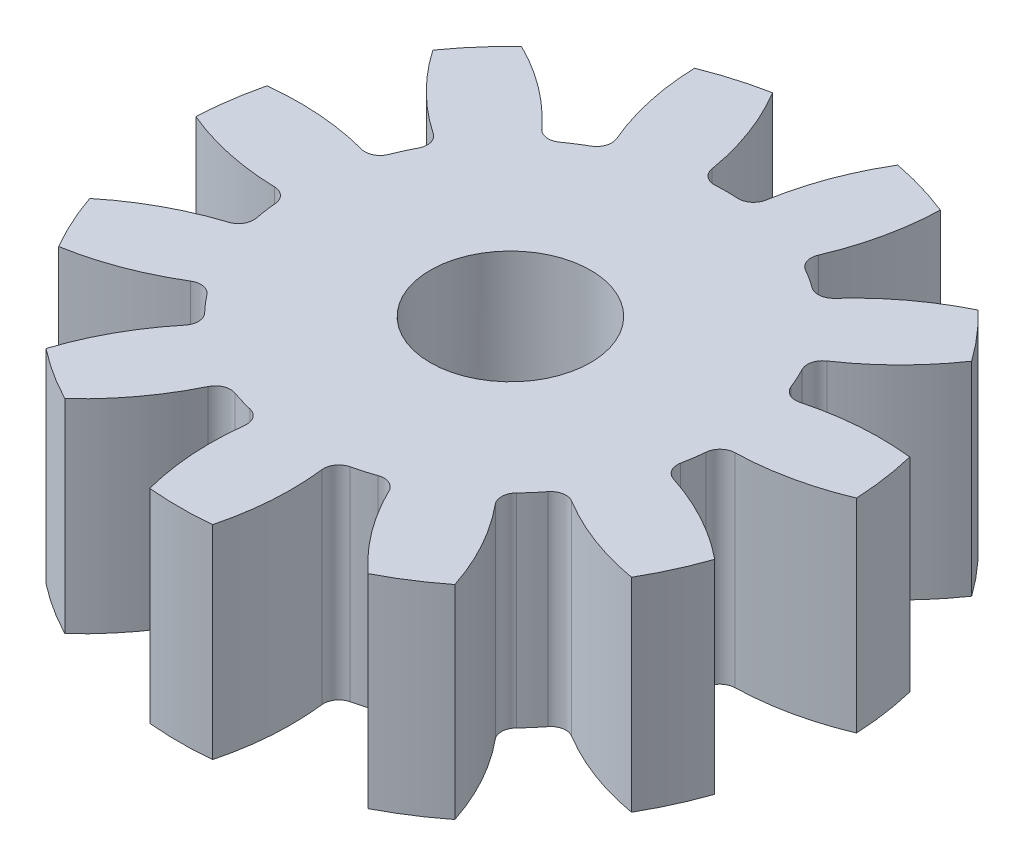
from build123d import *

# Parameters (mm, degrees)
SKETCH10_R               = 13
BOSS_EXTRUDE1_DEPTH      = 8
CUT_EXTRUDE1_DEPTH       = 9
FILLET1_R                = 0.6
CIRPATTERN1_COUNT        = 11
FILLET1_OF_CIRPATTERN1_R = 0.6
SKETCH12_R               = 3.15
CUT_EXTRUDE2_DEPTH       = 6
BOSS_EXTRUDE2_DEPTH      = 0.75


with BuildPart() as part:
    # Sketch10 → Boss-Extrude1 (new body)
    with BuildSketch(Plane(origin=(0, 0, 0), x_dir=(1, 0, 0), z_dir=(0, 1, 0))):
        Circle(SKETCH10_R)
    extrude(amount=BOSS_EXTRUDE1_DEPTH)

    # Sketch11 → Cut-Extrude1 (cut, through all)
    with BuildSketch(Plane(origin=(0, 8, 0), x_dir=(1, 0, 0), z_dir=(0, 1, 0))):
        with BuildLine():
            ThreePointArc((-3.063065397, 13.660806359), (-1.680040723, 11.18883567), (-0.986007978, 8.442617383))
            ThreePointArc((-0.986007978, 8.442617383), (0, 8.5), (0.986007978, 8.442617383))
            ThreePointArc((0.986007978, 8.442617383), (1.680040723, 11.18883567), (3.063065397, 13.660806359))
            ThreePointArc((3.063065397, 13.660806359), (0, 14), (-3.063065397, 13.660806359))
        make_face()
    cut_extrude1 = extrude(amount=-CUT_EXTRUDE1_DEPTH, mode=Mode.SUBTRACT)

    # Fillet1
    fillet1_edges = [part.edges().sort_by_distance(p)[0] for p in [
        (-0.986007978, 4, -8.442617383),
        (0.986007978, 4, -8.442617383),
    ]]
    fillet(fillet1_edges, radius=FILLET1_R)

    # CirPattern1: Cut-Extrude1 ×11 about axis
    cirpattern1_axis = Axis((0, 0, 0), (0, 1, 0))
    for i in range(1, CIRPATTERN1_COUNT):
        add(cut_extrude1.rotate(cirpattern1_axis, i * 360 / CIRPATTERN1_COUNT), mode=Mode.SUBTRACT)

    # Fillet1 of CirPattern1
    fillet1_of_cirpattern1_edges = [part.edges().sort_by_distance(p)[0] for p in [
        (-5.393906258, 4, -6.56930554),
        (-3.734940868, 4, -7.635457859),
        (-8.089277413, 4, -2.610285605),
        (-7.270072379, 4, -4.404094414),
        (-8.216360145, 4, 2.177481566),
        (-8.497007277, 4, 0.225537889),
        (-5.734806585, 4, 6.273913725),
        (-7.026202401, 4, 4.783563506),
        (-1.432492455, 4, 8.378422606),
        (-3.324627908, 4, 7.822841509),
        (3.324627908, 4, 7.822841509),
        (1.432492455, 4, 8.378422606),
        (7.026202401, 4, 4.783563506),
        (5.734806585, 4, 6.273913725),
        (8.497007277, 4, 0.225537889),
        (8.216360145, 4, 2.177481566),
        (7.270072379, 4, -4.404094414),
        (8.089277413, 4, -2.610285605),
        (3.734940868, 4, -7.635457859),
        (5.393906258, 4, -6.56930554),
    ]]
    fillet(fillet1_of_cirpattern1_edges, radius=FILLET1_OF_CIRPATTERN1_R)

    # Sketch12 → Cut-Extrude2 (cut)
    with BuildSketch(Plane(origin=(0, 8, 0), x_dir=(1, 0, 0), z_dir=(0, 1, 0))):
        Circle(SKETCH12_R)
    extrude(amount=-CUT_EXTRUDE2_DEPTH, mode=Mode.SUBTRACT)

    # Sketch13 → Boss-Extrude2 (add)
    with BuildSketch(Plane(origin=(0, 2, 0), x_dir=(1, 0, 0), z_dir=(0, 1, 0))):
        with BuildLine():
            Line((-0.375, 3.127598919), (-0.375, -3.127598919))
            ThreePointArc((-0.375, -3.127598919), (0, -3.15), (0.375, -3.127598919))
            Line((0.375, -3.127598919), (0.375, 3.127598919))
            ThreePointArc((0.375, 3.127598919), (0, 3.15), (-0.375, 3.127598919))
        make_face()
    extrude(amount=BOSS_EXTRUDE2_DEPTH)


solid = part.part
